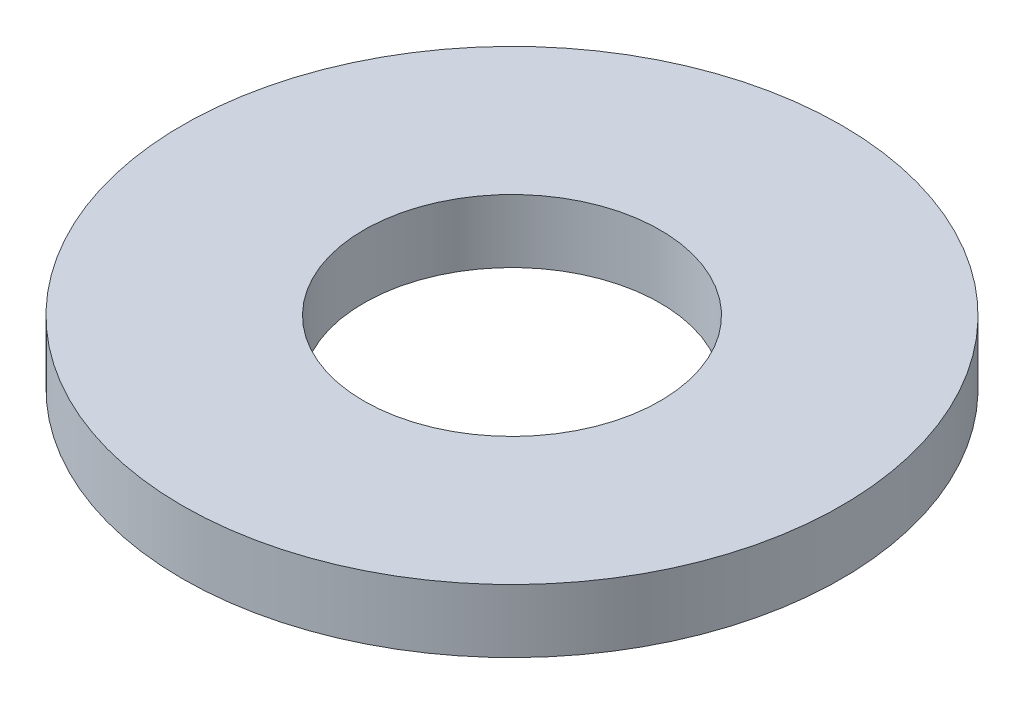
from build123d import *

# Parameters (mm, degrees)
SKETCH1_R           = 7.9375
BOSS_EXTRUDE1_DEPTH = 1.524
SKETCH5_R           = 3.5687
CUT_EXTRUDE1_DEPTH  = 2.524


with BuildPart() as part:
    # Sketch1 → Boss-Extrude1 (new body)
    with BuildSketch(Plane(origin=(0, 0, 0), x_dir=(1, 0, 0), z_dir=(0, 1, 0))):
        Circle(SKETCH1_R)
    extrude(amount=BOSS_EXTRUDE1_DEPTH)

    # Sketch5 → Cut-Extrude1 (cut, through all)
    with BuildSketch(Plane(origin=(0, 1.524, 0), x_dir=(-1, 0, 0), z_dir=(0, 1, 0))):
        Circle(SKETCH5_R)
    extrude(amount=-CUT_EXTRUDE1_DEPTH, mode=Mode.SUBTRACT)


solid = part.part
